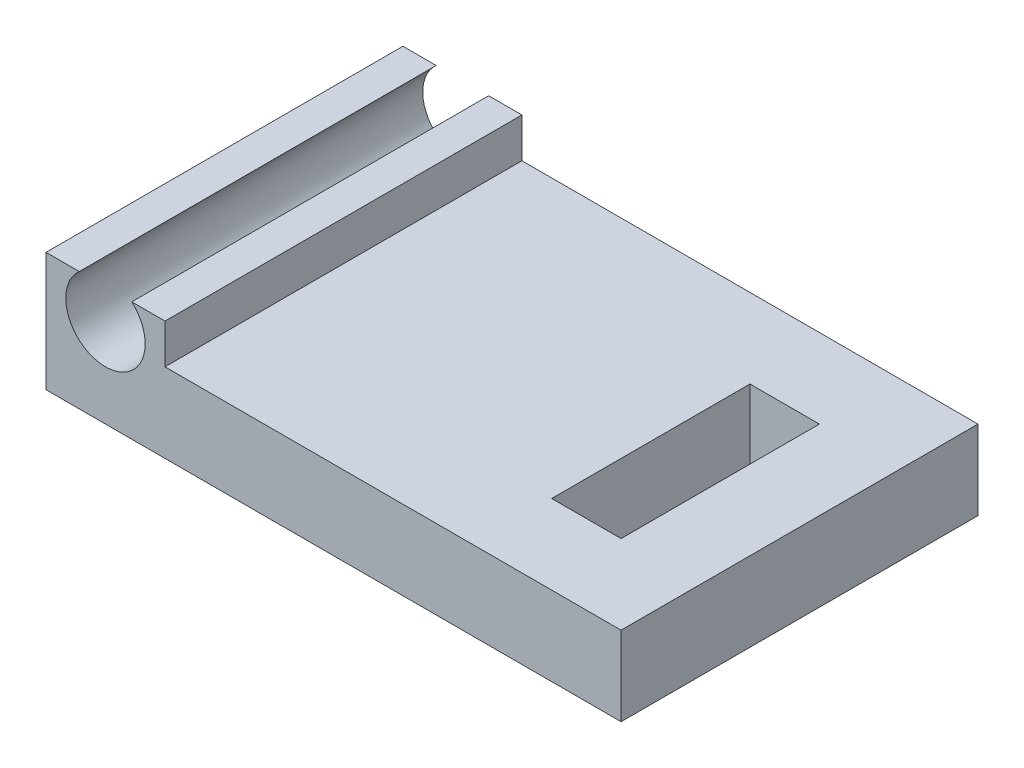
from build123d import *

# Parameters (mm, degrees)
SKETCH1_W           = 14.732
SKETCH1_H           = 9.144
SKETCH1_W_2         = 1.778
SKETCH1_H_2         = 5.08
BOSS_EXTRUDE1_DEPTH = 2.032
SKETCH2_W           = 3.048
SKETCH2_H           = 9.144
BOSS_EXTRUDE2_DEPTH = 1.016
SKETCH3_R           = 1.016
CUT_EXTRUDE1_DEPTH  = 10.144


with BuildPart() as part:
    # Sketch1 → Boss-Extrude1 (new body)
    with BuildSketch(Plane(origin=(0, 0, 0), x_dir=(1, 0, 0), z_dir=(0, 1, 0))):
        Rectangle(SKETCH1_W, SKETCH1_H)
        with Locations((4.445, 0)):
            Rectangle(SKETCH1_W_2, SKETCH1_H_2, mode=Mode.SUBTRACT)
    extrude(amount=BOSS_EXTRUDE1_DEPTH)

    # Sketch2 → Boss-Extrude2 (add)
    with BuildSketch(Plane(origin=(0, 2.032, 0), x_dir=(1, 0, 0), z_dir=(0, 1, 0))):
        with Locations((-5.842, 0)):
            Rectangle(SKETCH2_W, SKETCH2_H)
    extrude(amount=BOSS_EXTRUDE2_DEPTH)

    # Sketch3 → Cut-Extrude1 (cut, through all)
    with BuildSketch(Plane.XY.offset(4.572)):
        with Locations((-5.842, 2.286)):
            Circle(SKETCH3_R)
    extrude(amount=-CUT_EXTRUDE1_DEPTH, mode=Mode.SUBTRACT)


solid = part.part
